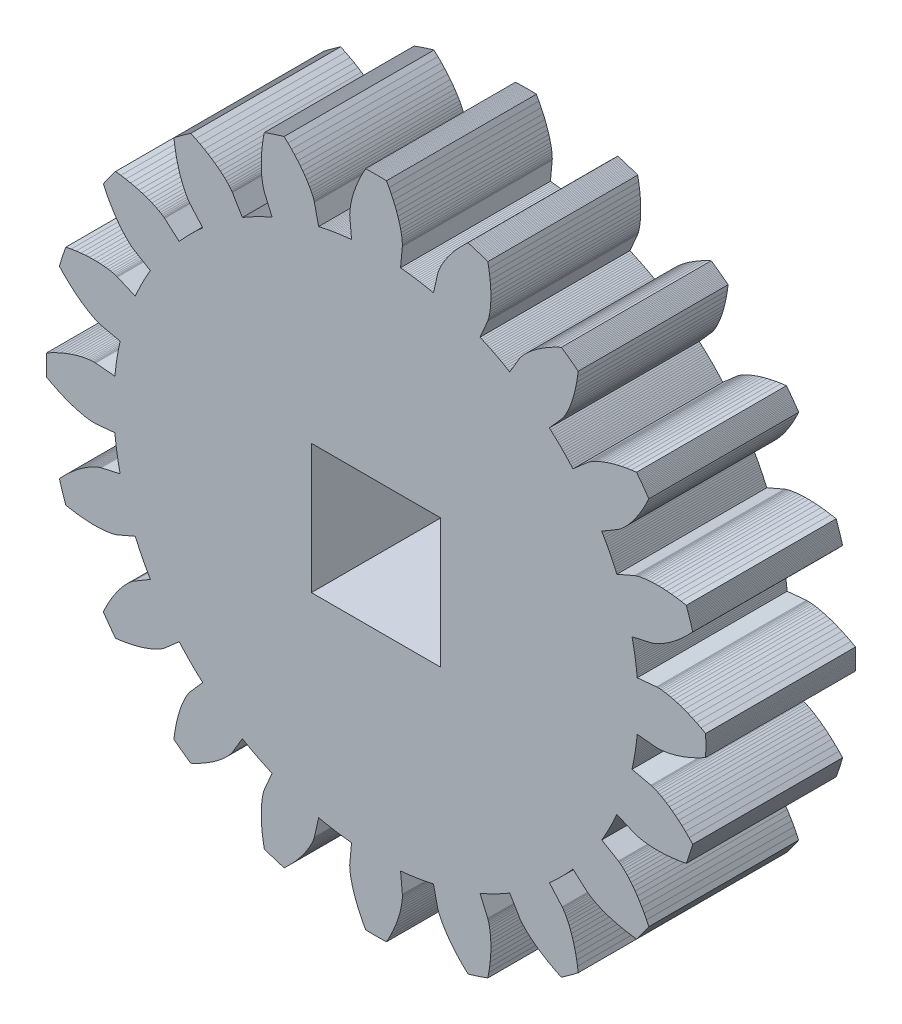
from build123d import *

# Parameters (mm, degrees)
BOSS_EXTRUDE1_DEPTH = 5
SKETCH4_W           = 4.313351366
SKETCH4_H           = 4.313351366
CUT_EXTRUDE2_DEPTH  = 6


with BuildPart() as part:
    # Sketch2 → Boss-Extrude1 (new body)
    with BuildSketch(Plane.XY):
        Polygon((8.7118261, -0.8164474), (9.3559299, -0.8768109), (9.3607367, -0.8771581), (9.3751806, -0.8777886), (9.3992749, -0.8780851), (9.4330031, -0.8774303), (9.4763191, -0.8752074), (9.5291472, -0.8708025), (9.5913822, -0.8636047), (9.6628896, -0.8530082), (9.7435058, -0.8384133), (9.8330384, -0.8192276), (9.9312664, -0.794867), (10.0379405, -0.7647573), (10.1527838, -0.7283355), (10.2754921, -0.6850503), (10.4057343, -0.634364), (10.5431529, -0.5757533), (10.6873651, -0.5087105), (10.8379627, -0.4327446), (10.9945134, -0.3473822), (10.9956076, -0.310826), (10.9965803, -0.2742663), (10.9974314, -0.2377036), (10.9981609, -0.2011383), (10.9987689, -0.1645707), (10.9992552, -0.1280013), (10.99962, -0.0914305), (10.9998632, -0.0548587), (10.9999848, -0.0182863), (10.9999848, 0.0182863), (10.9998632, 0.0548587), (10.99962, 0.0914305), (10.9992552, 0.1280013), (10.9987689, 0.1645707), (10.9981609, 0.2011383), (10.9974314, 0.2377036), (10.9965803, 0.2742663), (10.9956076, 0.310826), (10.9945134, 0.3473822), (10.8379627, 0.4327446), (10.6873651, 0.5087105), (10.5431529, 0.5757533), (10.4057343, 0.634364), (10.2754921, 0.6850503), (10.1527838, 0.7283355), (10.0379405, 0.7647573), (9.9312664, 0.794867), (9.8330384, 0.8192276), (9.7435058, 0.8384133), (9.6628896, 0.8530082), (9.5913822, 0.8636047), (9.5291472, 0.8708025), (9.4763191, 0.8752074), (9.4330031, 0.8774303), (9.3992749, 0.8780851), (9.3751806, 0.8777886), (9.3607367, 0.8771581), (9.3559299, 0.8768109), (8.7118261, 0.8164474), (8.7061617, 0.8747845), (8.7001067, 0.9330824), (8.6936614, 0.9913384), (8.6868259, 1.0495499), (8.6796007, 1.1077143), (8.6719861, 1.165829), (8.6639823, 1.2238915), (8.6555898, 1.281899), (8.6468089, 1.339849), (8.6376401, 1.3977388), (8.6280837, 1.455566), (8.6181401, 1.5133278), (8.6078099, 1.5710218), (8.5970934, 1.6286452), (8.5859912, 1.6861956), (8.5745037, 1.7436703), (8.5626315, 1.8010668), (8.5503751, 1.8583824), (8.5377351, 1.9156147), (9.1689676, 2.0572446), (9.1736464, 2.0583998), (9.1875782, 2.0622636), (9.2105849, 2.0694271), (9.2424599, 2.0804725), (9.282969, 2.0959719), (9.3318503, 2.1164861), (9.388815, 2.1425632), (9.4535481, 2.1747381), (9.5257087, 2.2135304), (9.6049305, 2.2594443), (9.690823, 2.3129667), (9.7829717, 2.3745668), (9.8809393, 2.4446946), (9.9842659, 2.5237802), (10.0924706, 2.6122327), (10.2050519, 2.7104395), (10.3214884, 2.818765), (10.4412405, 2.9375501), (10.5637507, 3.0671114), (10.5534948, 3.1022165), (10.5431223, 3.1372874), (10.5326332, 3.1723236), (10.5220277, 3.2073248), (10.5113059, 3.2422905), (10.5004679, 3.2772203), (10.4895139, 3.3121139), (10.4784439, 3.3469709), (10.467258, 3.3817909), (10.4559564, 3.4165736), (10.4445393, 3.4513184), (10.4330067, 3.4860251), (10.4213588, 3.5206933), (10.4095957, 3.5553225), (10.3977175, 3.5899125), (10.3857243, 3.6244627), (10.3736164, 3.6589729), (10.3613938, 3.6934427), (10.3490566, 3.7278716), (10.1737897, 3.7606792), (10.007088, 3.7863899), (9.8492168, 3.8055874), (9.7004121, 3.8188647), (9.5608816, 3.8268232), (9.4308032, 3.8300709), (9.3103257, 3.8292216), (9.1995682, 3.8248935), (9.09862, 3.8177077), (9.0075407, 3.8082874), (8.9263601, 3.7972561), (8.855078, 3.7852369), (8.7936647, 3.7728508), (8.742061, 3.7607154), (8.7001782, 3.749444), (8.6678984, 3.7396443), (8.645075, 3.7319167), (8.6315329, 3.7268536), (8.6270686, 3.7250381), (8.0331429, 3.4685899), (8.0097286, 3.5223214), (7.9859549, 3.5758949), (7.9618229, 3.6293079), (7.9373337, 3.6825581), (7.9124883, 3.7356431), (7.8872879, 3.7885604), (7.8617336, 3.8413077), (7.8358265, 3.8938827), (7.8095679, 3.946283), (7.7829588, 3.9985062), (7.7560006, 4.05055), (7.7286943, 4.102412), (7.7010412, 4.15409), (7.6730426, 4.2055816), (7.6446998, 4.2568845), (7.6160139, 4.3079964), (7.5869863, 4.358915), (7.5576182, 4.409638), (7.5279111, 4.4601631), (8.0844828, 4.7899227), (8.0885756, 4.7924672), (8.1006316, 4.800447), (8.1202986, 4.8143694), (8.1472004, 4.8347241), (8.1809372, 4.8619829), (8.2210868, 4.8965982), (8.2672052, 4.9390021), (8.3188275, 4.9896059), (8.3754688, 5.0487984), (8.4366251, 5.1169459), (8.5017743, 5.194391), (8.5703775, 5.2814517), (8.6418795, 5.3784208), (8.7157102, 5.4855654), (8.7912857, 5.6031259), (8.8680092, 5.7313156), (8.9452725, 5.8703201), (9.0224569, 6.0202969), (9.0989344, 6.1813747), (9.0783324, 6.2115925), (9.05763, 6.2417416), (9.0368276, 6.2718217), (9.0159252, 6.3018325), (8.9949232, 6.3317736), (8.9738217, 6.3616448), (8.952621, 6.3914456), (8.9313214, 6.4211757), (8.9099231, 6.4508349), (8.8884262, 6.4804228), (8.8668311, 6.509939), (8.845138, 6.5393833), (8.8233471, 6.5687553), (8.8014587, 6.5980546), (8.779473, 6.6272811), (8.7573902, 6.6564342), (8.7352106, 6.6855138), (8.7129345, 6.7145195), (8.6905621, 6.743451), (8.5137352, 6.7204924), (8.3472475, 6.6934311), (8.1911706, 6.662904), (8.0455461, 6.6295484), (7.9103853, 6.594), (7.7856698, 6.5568924), (7.6713514, 6.5188551), (7.5673522, 6.4805128), (7.4735653, 6.442484), (7.3898548, 6.4053797), (7.3160562, 6.3698021), (7.2519771, 6.3363438), (7.1973971, 6.3055862), (7.1520691, 6.2780983), (7.1157192, 6.2544361), (7.0880476, 6.235141), (7.0687293, 6.2207388), (7.0574145, 6.2117388), (7.0537298, 6.2086326), (6.5681196, 5.7812027), (6.5292474, 5.825069), (6.4900822, 5.8686739), (6.4506257, 5.9120155), (6.4108799, 5.9550919), (6.3708464, 5.997901), (6.330527, 6.040441), (6.2899236, 6.08271), (6.2490379, 6.1247061), (6.2078719, 6.1664273), (6.1664273, 6.2078719), (6.1247061, 6.2490379), (6.08271, 6.2899236), (6.040441, 6.330527), (5.997901, 6.3708464), (5.9550919, 6.4108799), (5.9120155, 6.4506257), (5.8686739, 6.4900822), (5.825069, 6.5292474), (5.7812027, 6.5681196), (6.2086326, 7.0537298), (6.2117388, 7.0574145), (6.2207388, 7.0687293), (6.235141, 7.0880476), (6.2544361, 7.1157192), (6.2780983, 7.1520691), (6.3055862, 7.1973971), (6.3363438, 7.2519771), (6.3698021, 7.3160562), (6.4053797, 7.3898548), (6.442484, 7.4735653), (6.4805128, 7.5673522), (6.5188551, 7.6713514), (6.5568924, 7.7856698), (6.594, 7.9103853), (6.6295484, 8.0455461), (6.662904, 8.1911706), (6.6934311, 8.3472475), (6.7204924, 8.5137352), (6.743451, 8.6905621), (6.7145195, 8.7129345), (6.6855138, 8.7352106), (6.6564342, 8.7573902), (6.6272811, 8.779473), (6.5980546, 8.8014587), (6.5687553, 8.8233471), (6.5393833, 8.845138), (6.509939, 8.8668311), (6.4804228, 8.8884262), (6.4508349, 8.9099231), (6.4211757, 8.9313214), (6.3914456, 8.952621), (6.3616448, 8.9738217), (6.3317736, 8.9949232), (6.3018325, 9.0159252), (6.2718217, 9.0368276), (6.2417416, 9.05763), (6.2115925, 9.0783324), (6.1813747, 9.0989344), (6.0202969, 9.0224569), (5.8703201, 8.9452725), (5.7313156, 8.8680092), (5.6031259, 8.7912857), (5.4855654, 8.7157102), (5.3784208, 8.6418795), (5.2814517, 8.5703775), (5.194391, 8.5017743), (5.1169459, 8.4366251), (5.0487984, 8.3754688), (4.9896059, 8.3188275), (4.9390021, 8.2672052), (4.8965982, 8.2210868), (4.8619829, 8.1809372), (4.8347241, 8.1472004), (4.8143694, 8.1202986), (4.800447, 8.1006316), (4.7924672, 8.0885756), (4.7899227, 8.0844828), (4.4601631, 7.5279111), (4.409638, 7.5576182), (4.358915, 7.5869863), (4.3079964, 7.6160139), (4.2568845, 7.6446998), (4.2055816, 7.6730426), (4.15409, 7.7010412), (4.102412, 7.7286943), (4.05055, 7.7560006), (3.9985062, 7.7829588), (3.946283, 7.8095679), (3.8938827, 7.8358265), (3.8413077, 7.8617336), (3.7885604, 7.8872879), (3.7356431, 7.9124883), (3.6825581, 7.9373337), (3.6293079, 7.9618229), (3.5758949, 7.9859549), (3.5223214, 8.0097286), (3.4685899, 8.0331429), (3.7250381, 8.6270686), (3.7268536, 8.6315329), (3.7319167, 8.645075), (3.7396443, 8.6678984), (3.749444, 8.7001782), (3.7607154, 8.742061), (3.7728508, 8.7936647), (3.7852369, 8.855078), (3.7972561, 8.9263601), (3.8082874, 9.0075407), (3.8177077, 9.09862), (3.8248935, 9.1995682), (3.8292216, 9.3103257), (3.8300709, 9.4308032), (3.8268232, 9.5608816), (3.8188647, 9.7004121), (3.8055874, 9.8492168), (3.7863899, 10.007088), (3.7606792, 10.1737897), (3.7278716, 10.3490566), (3.6934427, 10.3613938), (3.6589729, 10.3736164), (3.6244627, 10.3857243), (3.5899125, 10.3977175), (3.5553225, 10.4095957), (3.5206933, 10.4213588), (3.4860251, 10.4330067), (3.4513184, 10.4445393), (3.4165736, 10.4559564), (3.3817909, 10.467258), (3.3469709, 10.4784439), (3.3121139, 10.4895139), (3.2772203, 10.5004679), (3.2422905, 10.5113059), (3.2073248, 10.5220277), (3.1723236, 10.5326332), (3.1372874, 10.5431223), (3.1022165, 10.5534948), (3.0671114, 10.5637507), (2.9375501, 10.4412405), (2.818765, 10.3214884), (2.7104395, 10.2050519), (2.6122327, 10.0924706), (2.5237802, 9.9842659), (2.4446946, 9.8809393), (2.3745668, 9.7829717), (2.3129667, 9.690823), (2.2594443, 9.6049305), (2.2135304, 9.5257087), (2.1747381, 9.4535481), (2.1425632, 9.388815), (2.1164861, 9.3318503), (2.0959719, 9.282969), (2.0804725, 9.2424599), (2.0694271, 9.2105849), (2.0622636, 9.1875782), (2.0583998, 9.1736464), (2.0572446, 9.1689676), (1.9156147, 8.5377351), (1.8583824, 8.5503751), (1.8010668, 8.5626315), (1.7436703, 8.5745037), (1.6861956, 8.5859912), (1.6286452, 8.5970934), (1.5710218, 8.6078099), (1.5133278, 8.6181401), (1.455566, 8.6280837), (1.3977388, 8.6376401), (1.339849, 8.6468089), (1.281899, 8.6555898), (1.2238915, 8.6639823), (1.165829, 8.6719861), (1.1077143, 8.6796007), (1.0495499, 8.6868259), (0.9913384, 8.6936614), (0.9330824, 8.7001067), (0.8747845, 8.7061617), (0.8164474, 8.7118261), (0.8768109, 9.3559299), (0.8771581, 9.3607367), (0.8777886, 9.3751806), (0.8780851, 9.3992749), (0.8774303, 9.4330031), (0.8752074, 9.4763191), (0.8708025, 9.5291472), (0.8636047, 9.5913822), (0.8530082, 9.6628896), (0.8384133, 9.7435058), (0.8192276, 9.8330384), (0.794867, 9.9312664), (0.7647573, 10.0379405), (0.7283355, 10.1527838), (0.6850503, 10.2754921), (0.634364, 10.4057343), (0.5757533, 10.5431529), (0.5087105, 10.6873651), (0.4327446, 10.8379627), (0.3473822, 10.9945134), (0.310826, 10.9956076), (0.2742663, 10.9965803), (0.2377036, 10.9974314), (0.2011383, 10.9981609), (0.1645707, 10.9987689), (0.1280013, 10.9992552), (0.0914305, 10.99962), (0.0548587, 10.9998632), (0.0182863, 10.9999848), (-0.0182863, 10.9999848), (-0.0548587, 10.9998632), (-0.0914305, 10.99962), (-0.1280013, 10.9992552), (-0.1645707, 10.9987689), (-0.2011383, 10.9981609), (-0.2377036, 10.9974314), (-0.2742663, 10.9965803), (-0.310826, 10.9956076), (-0.3473822, 10.9945134), (-0.4327446, 10.8379627), (-0.5087105, 10.6873651), (-0.5757533, 10.5431529), (-0.634364, 10.4057343), (-0.6850503, 10.2754921), (-0.7283355, 10.1527838), (-0.7647573, 10.0379405), (-0.794867, 9.9312664), (-0.8192276, 9.8330384), (-0.8384133, 9.7435058), (-0.8530082, 9.6628896), (-0.8636047, 9.5913822), (-0.8708025, 9.5291472), (-0.8752074, 9.4763191), (-0.8774303, 9.4330031), (-0.8780851, 9.3992749), (-0.8777886, 9.3751806), (-0.8771581, 9.3607367), (-0.8768109, 9.3559299), (-0.8164474, 8.7118261), (-0.8747845, 8.7061617), (-0.9330824, 8.7001067), (-0.9913384, 8.6936614), (-1.0495499, 8.6868259), (-1.1077143, 8.6796007), (-1.165829, 8.6719861), (-1.2238915, 8.6639823), (-1.281899, 8.6555898), (-1.339849, 8.6468089), (-1.3977388, 8.6376401), (-1.455566, 8.6280837), (-1.5133278, 8.6181401), (-1.5710218, 8.6078099), (-1.6286452, 8.5970934), (-1.6861956, 8.5859912), (-1.7436703, 8.5745037), (-1.8010668, 8.5626315), (-1.8583824, 8.5503751), (-1.9156147, 8.5377351), (-2.0572446, 9.1689676), (-2.0583998, 9.1736464), (-2.0622636, 9.1875782), (-2.0694271, 9.2105849), (-2.0804725, 9.2424599), (-2.0959719, 9.282969), (-2.1164861, 9.3318503), (-2.1425632, 9.388815), (-2.1747381, 9.4535481), (-2.2135304, 9.5257087), (-2.2594443, 9.6049305), (-2.3129667, 9.690823), (-2.3745668, 9.7829717), (-2.4446946, 9.8809393), (-2.5237802, 9.9842659), (-2.6122327, 10.0924706), (-2.7104395, 10.2050519), (-2.818765, 10.3214884), (-2.9375501, 10.4412405), (-3.0671114, 10.5637507), (-3.1022165, 10.5534948), (-3.1372874, 10.5431223), (-3.1723236, 10.5326332), (-3.2073248, 10.5220277), (-3.2422905, 10.5113059), (-3.2772203, 10.5004679), (-3.3121139, 10.4895139), (-3.3469709, 10.4784439), (-3.3817909, 10.467258), (-3.4165736, 10.4559564), (-3.4513184, 10.4445393), (-3.4860251, 10.4330067), (-3.5206933, 10.4213588), (-3.5553225, 10.4095957), (-3.5899125, 10.3977175), (-3.6244627, 10.3857243), (-3.6589729, 10.3736164), (-3.6934427, 10.3613938), (-3.7278716, 10.3490566), (-3.7606792, 10.1737897), (-3.7863899, 10.007088), (-3.8055874, 9.8492168), (-3.8188647, 9.7004121), (-3.8268232, 9.5608816), (-3.8300709, 9.4308032), (-3.8292216, 9.3103257), (-3.8248935, 9.1995682), (-3.8177077, 9.09862), (-3.8082874, 9.0075407), (-3.7972561, 8.9263601), (-3.7852369, 8.855078), (-3.7728508, 8.7936647), (-3.7607154, 8.742061), (-3.749444, 8.7001782), (-3.7396443, 8.6678984), (-3.7319167, 8.645075), (-3.7268536, 8.6315329), (-3.7250381, 8.6270686), (-3.4685899, 8.0331429), (-3.5223214, 8.0097286), (-3.5758949, 7.9859549), (-3.6293079, 7.9618229), (-3.6825581, 7.9373337), (-3.7356431, 7.9124883), (-3.7885604, 7.8872879), (-3.8413077, 7.8617336), (-3.8938827, 7.8358265), (-3.946283, 7.8095679), (-3.9985062, 7.7829588), (-4.05055, 7.7560006), (-4.102412, 7.7286943), (-4.15409, 7.7010412), (-4.2055816, 7.6730426), (-4.2568845, 7.6446998), (-4.3079964, 7.6160139), (-4.358915, 7.5869863), (-4.409638, 7.5576182), (-4.4601631, 7.5279111), (-4.7899227, 8.0844828), (-4.7924672, 8.0885756), (-4.800447, 8.1006316), (-4.8143694, 8.1202986), (-4.8347241, 8.1472004), (-4.8619829, 8.1809372), (-4.8965982, 8.2210868), (-4.9390021, 8.2672052), (-4.9896059, 8.3188275), (-5.0487984, 8.3754688), (-5.1169459, 8.4366251), (-5.194391, 8.5017743), (-5.2814517, 8.5703775), (-5.3784208, 8.6418795), (-5.4855654, 8.7157102), (-5.6031259, 8.7912857), (-5.7313156, 8.8680092), (-5.8703201, 8.9452725), (-6.0202969, 9.0224569), (-6.1813747, 9.0989344), (-6.2115925, 9.0783324), (-6.2417416, 9.05763), (-6.2718217, 9.0368276), (-6.3018325, 9.0159252), (-6.3317736, 8.9949232), (-6.3616448, 8.9738217), (-6.3914456, 8.952621), (-6.4211757, 8.9313214), (-6.4508349, 8.9099231), (-6.4804228, 8.8884262), (-6.509939, 8.8668311), (-6.5393833, 8.845138), (-6.5687553, 8.8233471), (-6.5980546, 8.8014587), (-6.6272811, 8.779473), (-6.6564342, 8.7573902), (-6.6855138, 8.7352106), (-6.7145195, 8.7129345), (-6.743451, 8.6905621), (-6.7204924, 8.5137352), (-6.6934311, 8.3472475), (-6.662904, 8.1911706), (-6.6295484, 8.0455461), (-6.594, 7.9103853), (-6.5568924, 7.7856698), (-6.5188551, 7.6713514), (-6.4805128, 7.5673522), (-6.442484, 7.4735653), (-6.4053797, 7.3898548), (-6.3698021, 7.3160562), (-6.3363438, 7.2519771), (-6.3055862, 7.1973971), (-6.2780983, 7.1520691), (-6.2544361, 7.1157192), (-6.235141, 7.0880476), (-6.2207388, 7.0687293), (-6.2117388, 7.0574145), (-6.2086326, 7.0537298), (-5.7812027, 6.5681196), (-5.825069, 6.5292474), (-5.8686739, 6.4900822), (-5.9120155, 6.4506257), (-5.9550919, 6.4108799), (-5.997901, 6.3708464), (-6.040441, 6.330527), (-6.08271, 6.2899236), (-6.1247061, 6.2490379), (-6.1664273, 6.2078719), (-6.2078719, 6.1664273), (-6.2490379, 6.1247061), (-6.2899236, 6.08271), (-6.330527, 6.040441), (-6.3708464, 5.997901), (-6.4108799, 5.9550919), (-6.4506257, 5.9120155), (-6.4900822, 5.8686739), (-6.5292474, 5.825069), (-6.5681196, 5.7812027), (-7.0537298, 6.2086326), (-7.0574145, 6.2117388), (-7.0687293, 6.2207388), (-7.0880476, 6.235141), (-7.1157192, 6.2544361), (-7.1520691, 6.2780983), (-7.1973971, 6.3055862), (-7.2519771, 6.3363438), (-7.3160562, 6.3698021), (-7.3898548, 6.4053797), (-7.4735653, 6.442484), (-7.5673522, 6.4805128), (-7.6713514, 6.5188551), (-7.7856698, 6.5568924), (-7.9103853, 6.594), (-8.0455461, 6.6295484), (-8.1911706, 6.662904), (-8.3472475, 6.6934311), (-8.5137352, 6.7204924), (-8.6905621, 6.743451), (-8.7129345, 6.7145195), (-8.7352106, 6.6855138), (-8.7573902, 6.6564342), (-8.779473, 6.6272811), (-8.8014587, 6.5980546), (-8.8233471, 6.5687553), (-8.845138, 6.5393833), (-8.8668311, 6.509939), (-8.8884262, 6.4804228), (-8.9099231, 6.4508349), (-8.9313214, 6.4211757), (-8.952621, 6.3914456), (-8.9738217, 6.3616448), (-8.9949232, 6.3317736), (-9.0159252, 6.3018325), (-9.0368276, 6.2718217), (-9.05763, 6.2417416), (-9.0783324, 6.2115925), (-9.0989344, 6.1813747), (-9.0224569, 6.0202969), (-8.9452725, 5.8703201), (-8.8680092, 5.7313156), (-8.7912857, 5.6031259), (-8.7157102, 5.4855654), (-8.6418795, 5.3784208), (-8.5703775, 5.2814517), (-8.5017743, 5.194391), (-8.4366251, 5.1169459), (-8.3754688, 5.0487984), (-8.3188275, 4.9896059), (-8.2672052, 4.9390021), (-8.2210868, 4.8965982), (-8.1809372, 4.8619829), (-8.1472004, 4.8347241), (-8.1202986, 4.8143694), (-8.1006316, 4.800447), (-8.0885756, 4.7924672), (-8.0844828, 4.7899227), (-7.5279111, 4.4601631), (-7.5576182, 4.409638), (-7.5869863, 4.358915), (-7.6160139, 4.3079964), (-7.6446998, 4.2568845), (-7.6730426, 4.2055816), (-7.7010412, 4.15409), (-7.7286943, 4.102412), (-7.7560006, 4.05055), (-7.7829588, 3.9985062), (-7.8095679, 3.946283), (-7.8358265, 3.8938827), (-7.8617336, 3.8413077), (-7.8872879, 3.7885604), (-7.9124883, 3.7356431), (-7.9373337, 3.6825581), (-7.9618229, 3.6293079), (-7.9859549, 3.5758949), (-8.0097286, 3.5223214), (-8.0331429, 3.4685899), (-8.6270686, 3.7250381), (-8.6315329, 3.7268536), (-8.645075, 3.7319167), (-8.6678984, 3.7396443), (-8.7001782, 3.749444), (-8.742061, 3.7607154), (-8.7936647, 3.7728508), (-8.855078, 3.7852369), (-8.9263601, 3.7972561), (-9.0075407, 3.8082874), (-9.09862, 3.8177077), (-9.1995682, 3.8248935), (-9.3103257, 3.8292216), (-9.4308032, 3.8300709), (-9.5608816, 3.8268232), (-9.7004121, 3.8188647), (-9.8492168, 3.8055874), (-10.007088, 3.7863899), (-10.1737897, 3.7606792), (-10.3490566, 3.7278716), (-10.3613938, 3.6934427), (-10.3736164, 3.6589729), (-10.3857243, 3.6244627), (-10.3977175, 3.5899125), (-10.4095957, 3.5553225), (-10.4213588, 3.5206933), (-10.4330067, 3.4860251), (-10.4445393, 3.4513184), (-10.4559564, 3.4165736), (-10.467258, 3.3817909), (-10.4784439, 3.3469709), (-10.4895139, 3.3121139), (-10.5004679, 3.2772203), (-10.5113059, 3.2422905), (-10.5220277, 3.2073248), (-10.5326332, 3.1723236), (-10.5431223, 3.1372874), (-10.5534948, 3.1022165), (-10.5637507, 3.0671114), (-10.4412405, 2.9375501), (-10.3214884, 2.818765), (-10.2050519, 2.7104395), (-10.0924706, 2.6122327), (-9.9842659, 2.5237802), (-9.8809393, 2.4446946), (-9.7829717, 2.3745668), (-9.690823, 2.3129667), (-9.6049305, 2.2594443), (-9.5257087, 2.2135304), (-9.4535481, 2.1747381), (-9.388815, 2.1425632), (-9.3318503, 2.1164861), (-9.282969, 2.0959719), (-9.2424599, 2.0804725), (-9.2105849, 2.0694271), (-9.1875782, 2.0622636), (-9.1736464, 2.0583998), (-9.1689676, 2.0572446), (-8.5377351, 1.9156147), (-8.5503751, 1.8583824), (-8.5626315, 1.8010668), (-8.5745037, 1.7436703), (-8.5859912, 1.6861956), (-8.5970934, 1.6286452), (-8.6078099, 1.5710218), (-8.6181401, 1.5133278), (-8.6280837, 1.455566), (-8.6376401, 1.3977388), (-8.6468089, 1.339849), (-8.6555898, 1.281899), (-8.6639823, 1.2238915), (-8.6719861, 1.165829), (-8.6796007, 1.1077143), (-8.6868259, 1.0495499), (-8.6936614, 0.9913384), (-8.7001067, 0.9330824), (-8.7061617, 0.8747845), (-8.7118261, 0.8164474), (-9.3559299, 0.8768109), (-9.3607367, 0.8771581), (-9.3751806, 0.8777886), (-9.3992749, 0.8780851), (-9.4330031, 0.8774303), (-9.4763191, 0.8752074), (-9.5291472, 0.8708025), (-9.5913822, 0.8636047), (-9.6628896, 0.8530082), (-9.7435058, 0.8384133), (-9.8330384, 0.8192276), (-9.9312664, 0.794867), (-10.0379405, 0.7647573), (-10.1527838, 0.7283355), (-10.2754921, 0.6850503), (-10.4057343, 0.634364), (-10.5431529, 0.5757533), (-10.6873651, 0.5087105), (-10.8379627, 0.4327446), (-10.9945134, 0.3473822), (-10.9956076, 0.310826), (-10.9965803, 0.2742663), (-10.9974314, 0.2377036), (-10.9981609, 0.2011383), (-10.9987689, 0.1645707), (-10.9992552, 0.1280013), (-10.99962, 0.0914305), (-10.9998632, 0.0548587), (-10.9999848, 0.0182863), (-10.9999848, -0.0182863), (-10.9998632, -0.0548587), (-10.99962, -0.0914305), (-10.9992552, -0.1280013), (-10.9987689, -0.1645707), (-10.9981609, -0.2011383), (-10.9974314, -0.2377036), (-10.9965803, -0.2742663), (-10.9956076, -0.310826), (-10.9945134, -0.3473822), (-10.8379627, -0.4327446), (-10.6873651, -0.5087105), (-10.5431529, -0.5757533), (-10.4057343, -0.634364), (-10.2754921, -0.6850503), (-10.1527838, -0.7283355), (-10.0379405, -0.7647573), (-9.9312664, -0.794867), (-9.8330384, -0.8192276), (-9.7435058, -0.8384133), (-9.6628896, -0.8530082), (-9.5913822, -0.8636047), (-9.5291472, -0.8708025), (-9.4763191, -0.8752074), (-9.4330031, -0.8774303), (-9.3992749, -0.8780851), (-9.3751806, -0.8777886), (-9.3607367, -0.8771581), (-9.3559299, -0.8768109), (-8.7118261, -0.8164474), (-8.7061617, -0.8747845), (-8.7001067, -0.9330824), (-8.6936614, -0.9913384), (-8.6868259, -1.0495499), (-8.6796007, -1.1077143), (-8.6719861, -1.165829), (-8.6639823, -1.2238915), (-8.6555898, -1.281899), (-8.6468089, -1.339849), (-8.6376401, -1.3977388), (-8.6280837, -1.455566), (-8.6181401, -1.5133278), (-8.6078099, -1.5710218), (-8.5970934, -1.6286452), (-8.5859912, -1.6861956), (-8.5745037, -1.7436703), (-8.5626315, -1.8010668), (-8.5503751, -1.8583824), (-8.5377351, -1.9156147), (-9.1689676, -2.0572446), (-9.1736464, -2.0583998), (-9.1875782, -2.0622636), (-9.2105849, -2.0694271), (-9.2424599, -2.0804725), (-9.282969, -2.0959719), (-9.3318503, -2.1164861), (-9.388815, -2.1425632), (-9.4535481, -2.1747381), (-9.5257087, -2.2135304), (-9.6049305, -2.2594443), (-9.690823, -2.3129667), (-9.7829717, -2.3745668), (-9.8809393, -2.4446946), (-9.9842659, -2.5237802), (-10.0924706, -2.6122327), (-10.2050519, -2.7104395), (-10.3214884, -2.818765), (-10.4412405, -2.9375501), (-10.5637507, -3.0671114), (-10.5534948, -3.1022165), (-10.5431223, -3.1372874), (-10.5326332, -3.1723236), (-10.5220277, -3.2073248), (-10.5113059, -3.2422905), (-10.5004679, -3.2772203), (-10.4895139, -3.3121139), (-10.4784439, -3.3469709), (-10.467258, -3.3817909), (-10.4559564, -3.4165736), (-10.4445393, -3.4513184), (-10.4330067, -3.4860251), (-10.4213588, -3.5206933), (-10.4095957, -3.5553225), (-10.3977175, -3.5899125), (-10.3857243, -3.6244627), (-10.3736164, -3.6589729), (-10.3613938, -3.6934427), (-10.3490566, -3.7278716), (-10.1737897, -3.7606792), (-10.007088, -3.7863899), (-9.8492168, -3.8055874), (-9.7004121, -3.8188647), (-9.5608816, -3.8268232), (-9.4308032, -3.8300709), (-9.3103257, -3.8292216), (-9.1995682, -3.8248935), (-9.09862, -3.8177077), (-9.0075407, -3.8082874), (-8.9263601, -3.7972561), (-8.855078, -3.7852369), (-8.7936647, -3.7728508), (-8.742061, -3.7607154), (-8.7001782, -3.749444), (-8.6678984, -3.7396443), (-8.645075, -3.7319167), (-8.6315329, -3.7268536), (-8.6270686, -3.7250381), (-8.0331429, -3.4685899), (-8.0097286, -3.5223214), (-7.9859549, -3.5758949), (-7.9618229, -3.6293079), (-7.9373337, -3.6825581), (-7.9124883, -3.7356431), (-7.8872879, -3.7885604), (-7.8617336, -3.8413077), (-7.8358265, -3.8938827), (-7.8095679, -3.946283), (-7.7829588, -3.9985062), (-7.7560006, -4.05055), (-7.7286943, -4.102412), (-7.7010412, -4.15409), (-7.6730426, -4.2055816), (-7.6446998, -4.2568845), (-7.6160139, -4.3079964), (-7.5869863, -4.358915), (-7.5576182, -4.409638), (-7.5279111, -4.4601631), (-8.0844828, -4.7899227), (-8.0885756, -4.7924672), (-8.1006316, -4.800447), (-8.1202986, -4.8143694), (-8.1472004, -4.8347241), (-8.1809372, -4.8619829), (-8.2210868, -4.8965982), (-8.2672052, -4.9390021), (-8.3188275, -4.9896059), (-8.3754688, -5.0487984), (-8.4366251, -5.1169459), (-8.5017743, -5.194391), (-8.5703775, -5.2814517), (-8.6418795, -5.3784208), (-8.7157102, -5.4855654), (-8.7912857, -5.6031259), (-8.8680092, -5.7313156), (-8.9452725, -5.8703201), (-9.0224569, -6.0202969), (-9.0989344, -6.1813747), (-9.0783324, -6.2115925), (-9.05763, -6.2417416), (-9.0368276, -6.2718217), (-9.0159252, -6.3018325), (-8.9949232, -6.3317736), (-8.9738217, -6.3616448), (-8.952621, -6.3914456), (-8.9313214, -6.4211757), (-8.9099231, -6.4508349), (-8.8884262, -6.4804228), (-8.8668311, -6.509939), (-8.845138, -6.5393833), (-8.8233471, -6.5687553), (-8.8014587, -6.5980546), (-8.779473, -6.6272811), (-8.7573902, -6.6564342), (-8.7352106, -6.6855138), (-8.7129345, -6.7145195), (-8.6905621, -6.743451), (-8.5137352, -6.7204924), (-8.3472475, -6.6934311), (-8.1911706, -6.662904), (-8.0455461, -6.6295484), (-7.9103853, -6.594), (-7.7856698, -6.5568924), (-7.6713514, -6.5188551), (-7.5673522, -6.4805128), (-7.4735653, -6.442484), (-7.3898548, -6.4053797), (-7.3160562, -6.3698021), (-7.2519771, -6.3363438), (-7.1973971, -6.3055862), (-7.1520691, -6.2780983), (-7.1157192, -6.2544361), (-7.0880476, -6.235141), (-7.0687293, -6.2207388), (-7.0574145, -6.2117388), (-7.0537298, -6.2086326), (-6.5681196, -5.7812027), (-6.5292474, -5.825069), (-6.4900822, -5.8686739), (-6.4506257, -5.9120155), (-6.4108799, -5.9550919), (-6.3708464, -5.997901), (-6.330527, -6.040441), (-6.2899236, -6.08271), (-6.2490379, -6.1247061), (-6.2078719, -6.1664273), (-6.1664273, -6.2078719), (-6.1247061, -6.2490379), (-6.08271, -6.2899236), (-6.040441, -6.330527), (-5.997901, -6.3708464), (-5.9550919, -6.4108799), (-5.9120155, -6.4506257), (-5.8686739, -6.4900822), (-5.825069, -6.5292474), (-5.7812027, -6.5681196), (-6.2086326, -7.0537298), (-6.2117388, -7.0574145), (-6.2207388, -7.0687293), (-6.235141, -7.0880476), (-6.2544361, -7.1157192), (-6.2780983, -7.1520691), (-6.3055862, -7.1973971), (-6.3363438, -7.2519771), (-6.3698021, -7.3160562), (-6.4053797, -7.3898548), (-6.442484, -7.4735653), (-6.4805128, -7.5673522), (-6.5188551, -7.6713514), (-6.5568924, -7.7856698), (-6.594, -7.9103853), (-6.6295484, -8.0455461), (-6.662904, -8.1911706), (-6.6934311, -8.3472475), (-6.7204924, -8.5137352), (-6.743451, -8.6905621), (-6.7145195, -8.7129345), (-6.6855138, -8.7352106), (-6.6564342, -8.7573902), (-6.6272811, -8.779473), (-6.5980546, -8.8014587), (-6.5687553, -8.8233471), (-6.5393833, -8.845138), (-6.509939, -8.8668311), (-6.4804228, -8.8884262), (-6.4508349, -8.9099231), (-6.4211757, -8.9313214), (-6.3914456, -8.952621), (-6.3616448, -8.9738217), (-6.3317736, -8.9949232), (-6.3018325, -9.0159252), (-6.2718217, -9.0368276), (-6.2417416, -9.05763), (-6.2115925, -9.0783324), (-6.1813747, -9.0989344), (-6.0202969, -9.0224569), (-5.8703201, -8.9452725), (-5.7313156, -8.8680092), (-5.6031259, -8.7912857), (-5.4855654, -8.7157102), (-5.3784208, -8.6418795), (-5.2814517, -8.5703775), (-5.194391, -8.5017743), (-5.1169459, -8.4366251), (-5.0487984, -8.3754688), (-4.9896059, -8.3188275), (-4.9390021, -8.2672052), (-4.8965982, -8.2210868), (-4.8619829, -8.1809372), (-4.8347241, -8.1472004), (-4.8143694, -8.1202986), (-4.800447, -8.1006316), (-4.7924672, -8.0885756), (-4.7899227, -8.0844828), (-4.4601631, -7.5279111), (-4.409638, -7.5576182), (-4.358915, -7.5869863), (-4.3079964, -7.6160139), (-4.2568845, -7.6446998), (-4.2055816, -7.6730426), (-4.15409, -7.7010412), (-4.102412, -7.7286943), (-4.05055, -7.7560006), (-3.9985062, -7.7829588), (-3.946283, -7.8095679), (-3.8938827, -7.8358265), (-3.8413077, -7.8617336), (-3.7885604, -7.8872879), (-3.7356431, -7.9124883), (-3.6825581, -7.9373337), (-3.6293079, -7.9618229), (-3.5758949, -7.9859549), (-3.5223214, -8.0097286), (-3.4685899, -8.0331429), (-3.7250381, -8.6270686), (-3.7268536, -8.6315329), (-3.7319167, -8.645075), (-3.7396443, -8.6678984), (-3.749444, -8.7001782), (-3.7607154, -8.742061), (-3.7728508, -8.7936647), (-3.7852369, -8.855078), (-3.7972561, -8.9263601), (-3.8082874, -9.0075407), (-3.8177077, -9.09862), (-3.8248935, -9.1995682), (-3.8292216, -9.3103257), (-3.8300709, -9.4308032), (-3.8268232, -9.5608816), (-3.8188647, -9.7004121), (-3.8055874, -9.8492168), (-3.7863899, -10.007088), (-3.7606792, -10.1737897), (-3.7278716, -10.3490566), (-3.6934427, -10.3613938), (-3.6589729, -10.3736164), (-3.6244627, -10.3857243), (-3.5899125, -10.3977175), (-3.5553225, -10.4095957), (-3.5206933, -10.4213588), (-3.4860251, -10.4330067), (-3.4513184, -10.4445393), (-3.4165736, -10.4559564), (-3.3817909, -10.467258), (-3.3469709, -10.4784439), (-3.3121139, -10.4895139), (-3.2772203, -10.5004679), (-3.2422905, -10.5113059), (-3.2073248, -10.5220277), (-3.1723236, -10.5326332), (-3.1372874, -10.5431223), (-3.1022165, -10.5534948), (-3.0671114, -10.5637507), (-2.9375501, -10.4412405), (-2.818765, -10.3214884), (-2.7104395, -10.2050519), (-2.6122327, -10.0924706), (-2.5237802, -9.9842659), (-2.4446946, -9.8809393), (-2.3745668, -9.7829717), (-2.3129667, -9.690823), (-2.2594443, -9.6049305), (-2.2135304, -9.5257087), (-2.1747381, -9.4535481), (-2.1425632, -9.388815), (-2.1164861, -9.3318503), (-2.0959719, -9.282969), (-2.0804725, -9.2424599), (-2.0694271, -9.2105849), (-2.0622636, -9.1875782), (-2.0583998, -9.1736464), (-2.0572446, -9.1689676), (-1.9156147, -8.5377351), (-1.8583824, -8.5503751), (-1.8010668, -8.5626315), (-1.7436703, -8.5745037), (-1.6861956, -8.5859912), (-1.6286452, -8.5970934), (-1.5710218, -8.6078099), (-1.5133278, -8.6181401), (-1.455566, -8.6280837), (-1.3977388, -8.6376401), (-1.339849, -8.6468089), (-1.281899, -8.6555898), (-1.2238915, -8.6639823), (-1.165829, -8.6719861), (-1.1077143, -8.6796007), (-1.0495499, -8.6868259), (-0.9913384, -8.6936614), (-0.9330824, -8.7001067), (-0.8747845, -8.7061617), (-0.8164474, -8.7118261), (-0.8768109, -9.3559299), (-0.8771581, -9.3607367), (-0.8777886, -9.3751806), (-0.8780851, -9.3992749), (-0.8774303, -9.4330031), (-0.8752074, -9.4763191), (-0.8708025, -9.5291472), (-0.8636047, -9.5913822), (-0.8530082, -9.6628896), (-0.8384133, -9.7435058), (-0.8192276, -9.8330384), (-0.794867, -9.9312664), (-0.7647573, -10.0379405), (-0.7283355, -10.1527838), (-0.6850503, -10.2754921), (-0.634364, -10.4057343), (-0.5757533, -10.5431529), (-0.5087105, -10.6873651), (-0.4327446, -10.8379627), (-0.3473822, -10.9945134), (-0.310826, -10.9956076), (-0.2742663, -10.9965803), (-0.2377036, -10.9974314), (-0.2011383, -10.9981609), (-0.1645707, -10.9987689), (-0.1280013, -10.9992552), (-0.0914305, -10.99962), (-0.0548587, -10.9998632), (-0.0182863, -10.9999848), (0.0182863, -10.9999848), (0.0548587, -10.9998632), (0.0914305, -10.99962), (0.1280013, -10.9992552), (0.1645707, -10.9987689), (0.2011383, -10.9981609), (0.2377036, -10.9974314), (0.2742663, -10.9965803), (0.310826, -10.9956076), (0.3473822, -10.9945134), (0.4327446, -10.8379627), (0.5087105, -10.6873651), (0.5757533, -10.5431529), (0.634364, -10.4057343), (0.6850503, -10.2754921), (0.7283355, -10.1527838), (0.7647573, -10.0379405), (0.794867, -9.9312664), (0.8192276, -9.8330384), (0.8384133, -9.7435058), (0.8530082, -9.6628896), (0.8636047, -9.5913822), (0.8708025, -9.5291472), (0.8752074, -9.4763191), (0.8774303, -9.4330031), (0.8780851, -9.3992749), (0.8777886, -9.3751806), (0.8771581, -9.3607367), (0.8768109, -9.3559299), (0.8164474, -8.7118261), (0.8747845, -8.7061617), (0.9330824, -8.7001067), (0.9913384, -8.6936614), (1.0495499, -8.6868259), (1.1077143, -8.6796007), (1.165829, -8.6719861), (1.2238915, -8.6639823), (1.281899, -8.6555898), (1.339849, -8.6468089), (1.3977388, -8.6376401), (1.455566, -8.6280837), (1.5133278, -8.6181401), (1.5710218, -8.6078099), (1.6286452, -8.5970934), (1.6861956, -8.5859912), (1.7436703, -8.5745037), (1.8010668, -8.5626315), (1.8583824, -8.5503751), (1.9156147, -8.5377351), (2.0572446, -9.1689676), (2.0583998, -9.1736464), (2.0622636, -9.1875782), (2.0694271, -9.2105849), (2.0804725, -9.2424599), (2.0959719, -9.282969), (2.1164861, -9.3318503), (2.1425632, -9.388815), (2.1747381, -9.4535481), (2.2135304, -9.5257087), (2.2594443, -9.6049305), (2.3129667, -9.690823), (2.3745668, -9.7829717), (2.4446946, -9.8809393), (2.5237802, -9.9842659), (2.6122327, -10.0924706), (2.7104395, -10.2050519), (2.818765, -10.3214884), (2.9375501, -10.4412405), (3.0671114, -10.5637507), (3.1022165, -10.5534948), (3.1372874, -10.5431223), (3.1723236, -10.5326332), (3.2073248, -10.5220277), (3.2422905, -10.5113059), (3.2772203, -10.5004679), (3.3121139, -10.4895139), (3.3469709, -10.4784439), (3.3817909, -10.467258), (3.4165736, -10.4559564), (3.4513184, -10.4445393), (3.4860251, -10.4330067), (3.5206933, -10.4213588), (3.5553225, -10.4095957), (3.5899125, -10.3977175), (3.6244627, -10.3857243), (3.6589729, -10.3736164), (3.6934427, -10.3613938), (3.7278716, -10.3490566), (3.7606792, -10.1737897), (3.7863899, -10.007088), (3.8055874, -9.8492168), (3.8188647, -9.7004121), (3.8268232, -9.5608816), (3.8300709, -9.4308032), (3.8292216, -9.3103257), (3.8248935, -9.1995682), (3.8177077, -9.09862), (3.8082874, -9.0075407), (3.7972561, -8.9263601), (3.7852369, -8.855078), (3.7728508, -8.7936647), (3.7607154, -8.742061), (3.749444, -8.7001782), (3.7396443, -8.6678984), (3.7319167, -8.645075), (3.7268536, -8.6315329), (3.7250381, -8.6270686), (3.4685899, -8.0331429), (3.5223214, -8.0097286), (3.5758949, -7.9859549), (3.6293079, -7.9618229), (3.6825581, -7.9373337), (3.7356431, -7.9124883), (3.7885604, -7.8872879), (3.8413077, -7.8617336), (3.8938827, -7.8358265), (3.946283, -7.8095679), (3.9985062, -7.7829588), (4.05055, -7.7560006), (4.102412, -7.7286943), (4.15409, -7.7010412), (4.2055816, -7.6730426), (4.2568845, -7.6446998), (4.3079964, -7.6160139), (4.358915, -7.5869863), (4.409638, -7.5576182), (4.4601631, -7.5279111), (4.7899227, -8.0844828), (4.7924672, -8.0885756), (4.800447, -8.1006316), (4.8143694, -8.1202986), (4.8347241, -8.1472004), (4.8619829, -8.1809372), (4.8965982, -8.2210868), (4.9390021, -8.2672052), (4.9896059, -8.3188275), (5.0487984, -8.3754688), (5.1169459, -8.4366251), (5.194391, -8.5017743), (5.2814517, -8.5703775), (5.3784208, -8.6418795), (5.4855654, -8.7157102), (5.6031259, -8.7912857), (5.7313156, -8.8680092), (5.8703201, -8.9452725), (6.0202969, -9.0224569), (6.1813747, -9.0989344), (6.2115925, -9.0783324), (6.2417416, -9.05763), (6.2718217, -9.0368276), (6.3018325, -9.0159252), (6.3317736, -8.9949232), (6.3616448, -8.9738217), (6.3914456, -8.952621), (6.4211757, -8.9313214), (6.4508349, -8.9099231), (6.4804228, -8.8884262), (6.509939, -8.8668311), (6.5393833, -8.845138), (6.5687553, -8.8233471), (6.5980546, -8.8014587), (6.6272811, -8.779473), (6.6564342, -8.7573902), (6.6855138, -8.7352106), (6.7145195, -8.7129345), (6.743451, -8.6905621), (6.7204924, -8.5137352), (6.6934311, -8.3472475), (6.662904, -8.1911706), (6.6295484, -8.0455461), (6.594, -7.9103853), (6.5568924, -7.7856698), (6.5188551, -7.6713514), (6.4805128, -7.5673522), (6.442484, -7.4735653), (6.4053797, -7.3898548), (6.3698021, -7.3160562), (6.3363438, -7.2519771), (6.3055862, -7.1973971), (6.2780983, -7.1520691), (6.2544361, -7.1157192), (6.235141, -7.0880476), (6.2207388, -7.0687293), (6.2117388, -7.0574145), (6.2086326, -7.0537298), (5.7812027, -6.5681196), (5.825069, -6.5292474), (5.8686739, -6.4900822), (5.9120155, -6.4506257), (5.9550919, -6.4108799), (5.997901, -6.3708464), (6.040441, -6.330527), (6.08271, -6.2899236), (6.1247061, -6.2490379), (6.1664273, -6.2078719), (6.2078719, -6.1664273), (6.2490379, -6.1247061), (6.2899236, -6.08271), (6.330527, -6.040441), (6.3708464, -5.997901), (6.4108799, -5.9550919), (6.4506257, -5.9120155), (6.4900822, -5.8686739), (6.5292474, -5.825069), (6.5681196, -5.7812027), (7.0537298, -6.2086326), (7.0574145, -6.2117388), (7.0687293, -6.2207388), (7.0880476, -6.235141), (7.1157192, -6.2544361), (7.1520691, -6.2780983), (7.1973971, -6.3055862), (7.2519771, -6.3363438), (7.3160562, -6.3698021), (7.3898548, -6.4053797), (7.4735653, -6.442484), (7.5673522, -6.4805128), (7.6713514, -6.5188551), (7.7856698, -6.5568924), (7.9103853, -6.594), (8.0455461, -6.6295484), (8.1911706, -6.662904), (8.3472475, -6.6934311), (8.5137352, -6.7204924), (8.6905621, -6.743451), (8.7129345, -6.7145195), (8.7352106, -6.6855138), (8.7573902, -6.6564342), (8.779473, -6.6272811), (8.8014587, -6.5980546), (8.8233471, -6.5687553), (8.845138, -6.5393833), (8.8668311, -6.509939), (8.8884262, -6.4804228), (8.9099231, -6.4508349), (8.9313214, -6.4211757), (8.952621, -6.3914456), (8.9738217, -6.3616448), (8.9949232, -6.3317736), (9.0159252, -6.3018325), (9.0368276, -6.2718217), (9.05763, -6.2417416), (9.0783324, -6.2115925), (9.0989344, -6.1813747), (9.0224569, -6.0202969), (8.9452725, -5.8703201), (8.8680092, -5.7313156), (8.7912857, -5.6031259), (8.7157102, -5.4855654), (8.6418795, -5.3784208), (8.5703775, -5.2814517), (8.5017743, -5.194391), (8.4366251, -5.1169459), (8.3754688, -5.0487984), (8.3188275, -4.9896059), (8.2672052, -4.9390021), (8.2210868, -4.8965982), (8.1809372, -4.8619829), (8.1472004, -4.8347241), (8.1202986, -4.8143694), (8.1006316, -4.800447), (8.0885756, -4.7924672), (8.0844828, -4.7899227), (7.5279111, -4.4601631), (7.5576182, -4.409638), (7.5869863, -4.358915), (7.6160139, -4.3079964), (7.6446998, -4.2568845), (7.6730426, -4.2055816), (7.7010412, -4.15409), (7.7286943, -4.102412), (7.7560006, -4.05055), (7.7829588, -3.9985062), (7.8095679, -3.946283), (7.8358265, -3.8938827), (7.8617336, -3.8413077), (7.8872879, -3.7885604), (7.9124883, -3.7356431), (7.9373337, -3.6825581), (7.9618229, -3.6293079), (7.9859549, -3.5758949), (8.0097286, -3.5223214), (8.0331429, -3.4685899), (8.6270686, -3.7250381), (8.6315329, -3.7268536), (8.645075, -3.7319167), (8.6678984, -3.7396443), (8.7001782, -3.749444), (8.742061, -3.7607154), (8.7936647, -3.7728508), (8.855078, -3.7852369), (8.9263601, -3.7972561), (9.0075407, -3.8082874), (9.09862, -3.8177077), (9.1995682, -3.8248935), (9.3103257, -3.8292216), (9.4308032, -3.8300709), (9.5608816, -3.8268232), (9.7004121, -3.8188647), (9.8492168, -3.8055874), (10.007088, -3.7863899), (10.1737897, -3.7606792), (10.3490566, -3.7278716), (10.3613938, -3.6934427), (10.3736164, -3.6589729), (10.3857243, -3.6244627), (10.3977175, -3.5899125), (10.4095957, -3.5553225), (10.4213588, -3.5206933), (10.4330067, -3.4860251), (10.4445393, -3.4513184), (10.4559564, -3.4165736), (10.467258, -3.3817909), (10.4784439, -3.3469709), (10.4895139, -3.3121139), (10.5004679, -3.2772203), (10.5113059, -3.2422905), (10.5220277, -3.2073248), (10.5326332, -3.1723236), (10.5431223, -3.1372874), (10.5534948, -3.1022165), (10.5637507, -3.0671114), (10.4412405, -2.9375501), (10.3214884, -2.818765), (10.2050519, -2.7104395), (10.0924706, -2.6122327), (9.9842659, -2.5237802), (9.8809393, -2.4446946), (9.7829717, -2.3745668), (9.690823, -2.3129667), (9.6049305, -2.2594443), (9.5257087, -2.2135304), (9.4535481, -2.1747381), (9.388815, -2.1425632), (9.3318503, -2.1164861), (9.282969, -2.0959719), (9.2424599, -2.0804725), (9.2105849, -2.0694271), (9.1875782, -2.0622636), (9.1736464, -2.0583998), (9.1689676, -2.0572446), (8.5377351, -1.9156147), (8.5503751, -1.8583824), (8.5626315, -1.8010668), (8.5745037, -1.7436703), (8.5859912, -1.6861956), (8.5970934, -1.6286452), (8.6078099, -1.5710218), (8.6181401, -1.5133278), (8.6280837, -1.455566), (8.6376401, -1.3977388), (8.6468089, -1.339849), (8.6555898, -1.281899), (8.6639823, -1.2238915), (8.6719861, -1.165829), (8.6796007, -1.1077143), (8.6868259, -1.0495499), (8.6936614, -0.9913384), (8.7001067, -0.9330824), (8.7061617, -0.8747845), align=None)
    extrude(amount=BOSS_EXTRUDE1_DEPTH)

    # Sketch4 → Cut-Extrude2 (cut, through all)
    with BuildSketch(Plane(origin=(0, 0, 0), x_dir=(-1, 0, 0), z_dir=(0, 0, -1))):
        Rectangle(SKETCH4_W, SKETCH4_H)
    extrude(amount=-CUT_EXTRUDE2_DEPTH, mode=Mode.SUBTRACT)


solid = part.part
